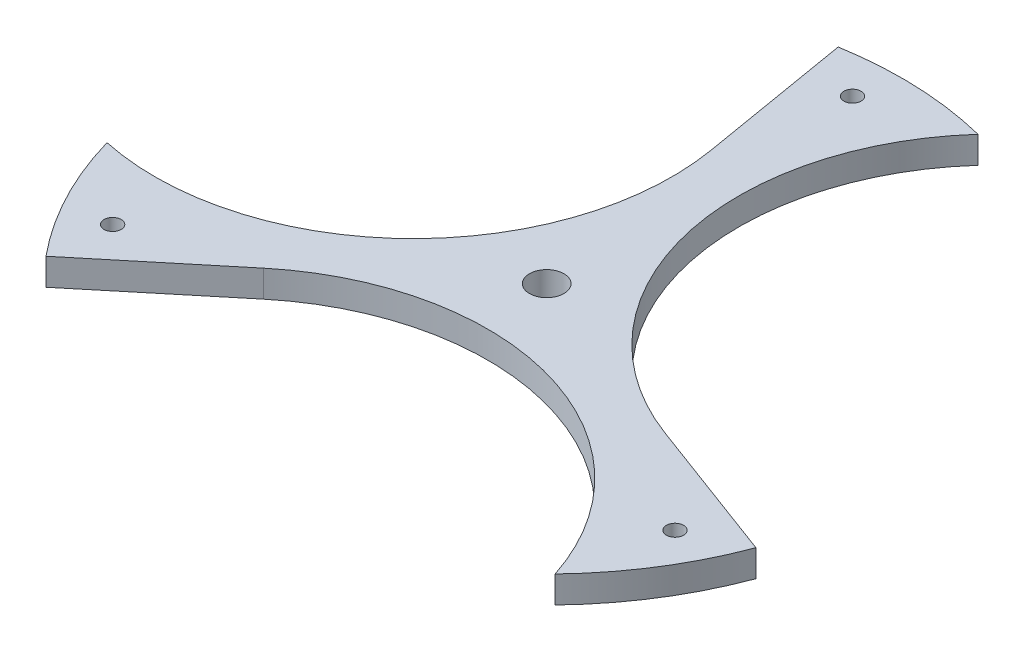
from build123d import *

# Parameters (mm, degrees)
SKETCH1_R           = 3.175
SKETCH1_R_2         = 1.5875
BOSS_EXTRUDE1_DEPTH = 2.4765


with BuildPart() as part:
    # Sketch1 → Boss-Extrude1 (new, symmetric)
    with BuildSketch(Plane(origin=(0, 0, 0), x_dir=(1, 0, 0), z_dir=(0, 1, 0))):
        with BuildLine():
            Line((34.700549349, -12.916534941), (61.399556839, -22.854667611))
            ThreePointArc((61.399556839, -22.854667611), (55.420174256, -34.940602415), (47.093148029, -45.546424892))
            ThreePointArc((47.093148029, -45.546424892), (15.086508303, -14.560725649), (-28.536322062, -23.593289791))
            Line((-28.536322062, -23.593289791), (-50.492501165, -41.746242199))
            ThreePointArc((-50.492501165, -41.746242199), (-57.969536443, -30.52497758), (-62.990935022, -18.010650091))
            ThreePointArc((-62.990935022, -18.010650091), (-20.153212462, -5.78493662), (-6.164227287, 36.509824732))
            Line((-6.164227287, 36.509824732), (-10.907055674, 64.600909809))
            ThreePointArc((-10.907055674, 64.600909809), (2.549362187, 65.465579995), (15.897786993, 63.557074983))
            ThreePointArc((15.897786993, 63.557074983), (5.066704158, 20.34566227), (34.700549349, -12.916534941))
        make_face()
        Circle(SKETCH1_R, mode=Mode.SUBTRACT)
        with Locations((-1.743506635, 58.073174541)):
            Circle(SKETCH1_R_2, mode=Mode.SUBTRACT)
        with Locations((-49.421091113, -30.546508308)):
            Circle(SKETCH1_R_2, mode=Mode.SUBTRACT)
        with Locations((51.164597749, -27.526666233)):
            Circle(SKETCH1_R_2, mode=Mode.SUBTRACT)
    extrude(amount=BOSS_EXTRUDE1_DEPTH, both=True)


solid = part.part
